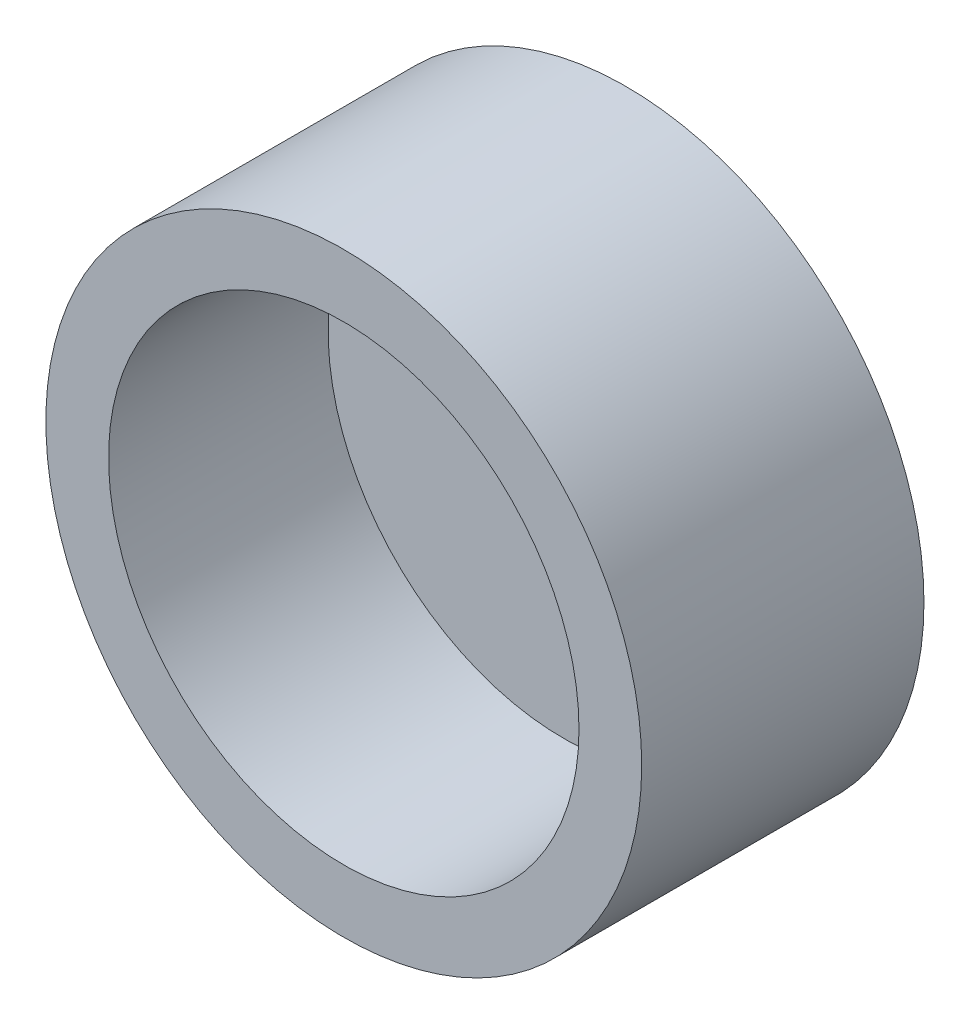
from build123d import *

# Parameters (mm, degrees)
SKETCH1_R           = 9.5
BOSS_EXTRUDE1_DEPTH = 9
SKETCH2_R           = 7.5
CUT_EXTRUDE1_DEPTH  = 7


with BuildPart() as part:
    # Sketch1 → Boss-Extrude1 (new body)
    with BuildSketch(Plane.XY):
        Circle(SKETCH1_R)
    extrude(amount=BOSS_EXTRUDE1_DEPTH)

    # Sketch2 → Cut-Extrude1 (cut)
    with BuildSketch(Plane.XY.offset(9)):
        Circle(SKETCH2_R)
    extrude(amount=-CUT_EXTRUDE1_DEPTH, mode=Mode.SUBTRACT)


solid = part.part
